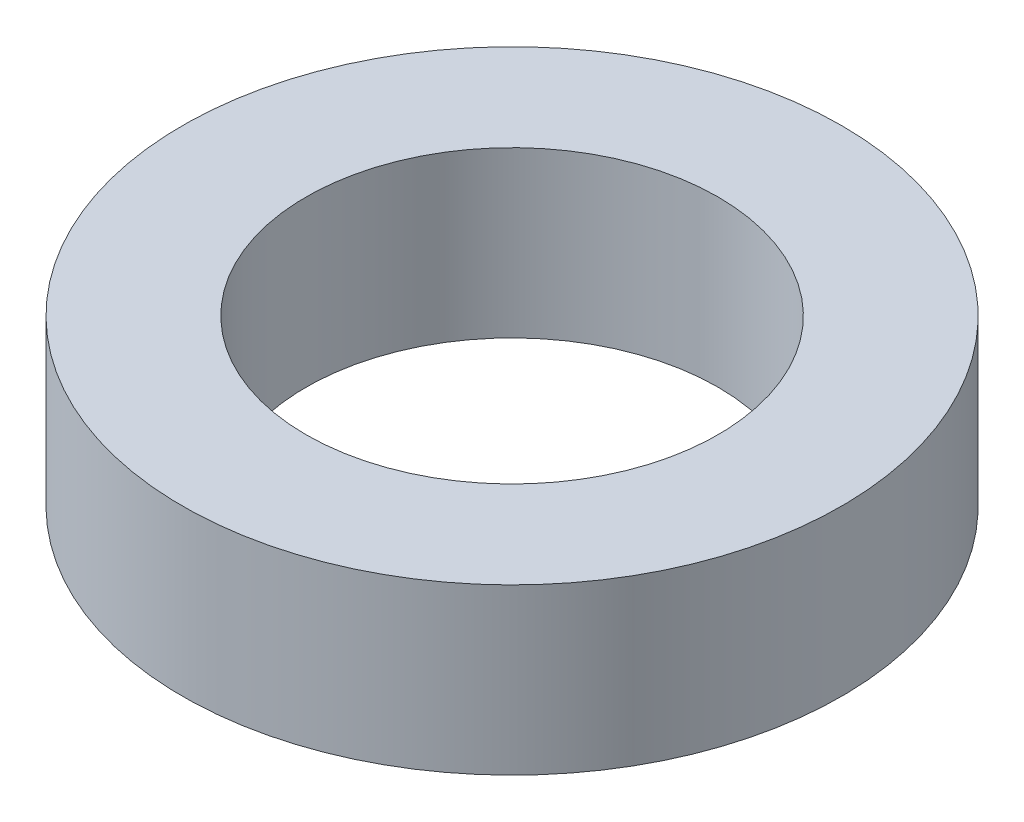
from build123d import *

# Parameters (mm, degrees)
SKETCH_1_W = 1.35
SKETCH_1_H = 1.8


with BuildPart() as part:
    # Эскиз1 → Повернуть1 (revolve)
    with BuildSketch(Plane.XY):
        with Locations((2.925, 0.9)):
            Rectangle(SKETCH_1_W, SKETCH_1_H)
    revolve(axis=Axis((0, 0, 0), (0, 1, 0)))


solid = part.part
